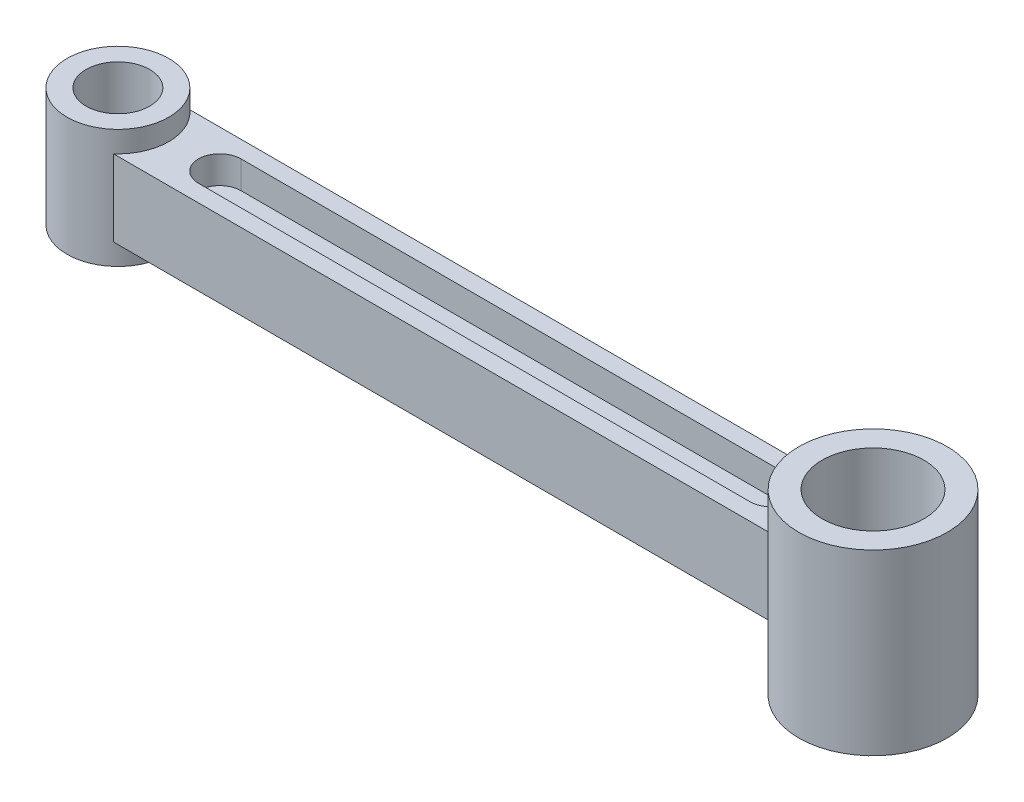
from build123d import *

# Parameters (mm, degrees)
SKETCH1_R           = 7.5
BOSS_EXTRUDE1_DEPTH = 14
SKETCH1_6_R         = 12
BOSS_EXTRUDE4_DEPTH = 21
BOSS_EXTRUDE5_DEPTH = 9
CUT_EXTRUDE2_START  = -2.5
CUT_EXTRUDE2_DEPTH  = 18


with BuildPart() as part:
    # Sketch1 → Boss-Extrude1 (new, symmetric)
    with BuildSketch(Plane(origin=(0, 0, 0), x_dir=(1, 0, 0), z_dir=(0, 1, 0))):
        with BuildLine():
            ThreePointArc((12, 0), (10.937253933, 4.937253933), (7.937253933, 9))
            ThreePointArc((7.937253933, 9), (-12, 0), (7.937253933, -9))
            ThreePointArc((7.937253933, -9), (10.937253933, -4.937253933), (12, 0))
        make_face()
        Circle(SKETCH1_R, mode=Mode.SUBTRACT)
    extrude(amount=BOSS_EXTRUDE1_DEPTH, both=True)



with BuildPart() as body_2:
    # Sketch1_6 → Boss-Extrude4 (new, symmetric)
    with BuildSketch(Plane(origin=(0, 0, 0), x_dir=(1, 0, 0), z_dir=(0, 1, 0))):
        with BuildLine():
            ThreePointArc((195.5, 0), (182.669272275, 16.865583193), (162.99166898, 9))
            ThreePointArc((162.99166898, 9), (160.5, 0), (162.99166898, -9))
            ThreePointArc((162.99166898, -9), (182.669272275, -16.865583193), (195.5, 0))
        make_face()
        with Locations((178, 0)):
            Circle(SKETCH1_6_R, mode=Mode.SUBTRACT)
    extrude(amount=BOSS_EXTRUDE4_DEPTH, both=True)


with BuildPart() as part_1:
    add(part.part)

    add(body_2.part)  # Boss-Extrude5 merges body 2
    # Sketch1_7 → Boss-Extrude5 (add, symmetric)
    with BuildSketch(Plane(origin=(0, 0, 0), x_dir=(1, 0, 0), z_dir=(0, 1, 0))):
        with BuildLine():
            Line((162.99166898, 9), (7.937253933, 9))
            ThreePointArc((7.937253933, 9), (10.937253933, 4.937253933), (12, 0))
            ThreePointArc((12, 0), (10.937253933, -4.937253933), (7.937253933, -9))
            Line((7.937253933, -9), (162.99166898, -9))
            ThreePointArc((162.99166898, -9), (160.5, 0), (162.99166898, 9))
        make_face()
    extrude(amount=BOSS_EXTRUDE5_DEPTH, both=True)

    # Sketch3 → Cut-Extrude2 (cut)
    with BuildSketch(Plane(origin=(0, 0, 0), x_dir=(1, 0, 0), z_dir=(0, 1, 0)).offset(CUT_EXTRUDE2_START)):
        with BuildLine():
            Line((24, 5), (154, 5))
            ThreePointArc((154, 5), (159, 0), (154, -5))
            Line((154, -5), (24, -5))
            ThreePointArc((24, -5), (19, 0), (24, 5))
        make_face()
    cut_extrude2 = extrude(amount=-CUT_EXTRUDE2_DEPTH, mode=Mode.SUBTRACT)

    # Mirror2: Cut-Extrude2 across plane
    add(cut_extrude2.mirror(Plane.ZX), mode=Mode.SUBTRACT)


solid = part_1.part
